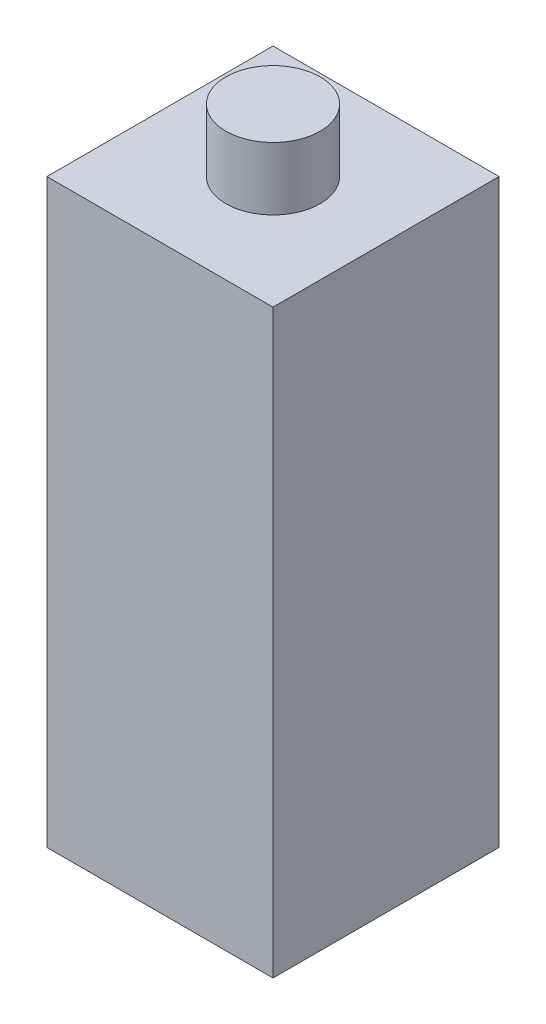
from build123d import *

# Parameters (mm, degrees)
SKETCH1_W                = 72
SKETCH1_H                = 72
BOSS_EXTRUDE1_DEPTH      = 185
SKETCH2_R                = 15
BOSS_EXTRUDE2_DEPTH      = 20
BOSS_EXTRUDE2_DEPTH_BACK = 205


with BuildPart() as part:
    # Sketch1 → Boss-Extrude1 (new body)
    with BuildSketch(Plane(origin=(0, 0, 0), x_dir=(1, 0, 0), z_dir=(0, 1, 0))):
        Rectangle(SKETCH1_W, SKETCH1_H)
    extrude(amount=BOSS_EXTRUDE1_DEPTH)

    # Sketch2 → Boss-Extrude2 (add, two sides)
    with BuildSketch(Plane(origin=(0, 185, 0), x_dir=(1, 0, 0), z_dir=(0, 1, 0))) as boss_extrude2_sk:
        Circle(SKETCH2_R)
    extrude(amount=BOSS_EXTRUDE2_DEPTH)
    extrude(boss_extrude2_sk.sketch, amount=-BOSS_EXTRUDE2_DEPTH_BACK)


solid = part.part
